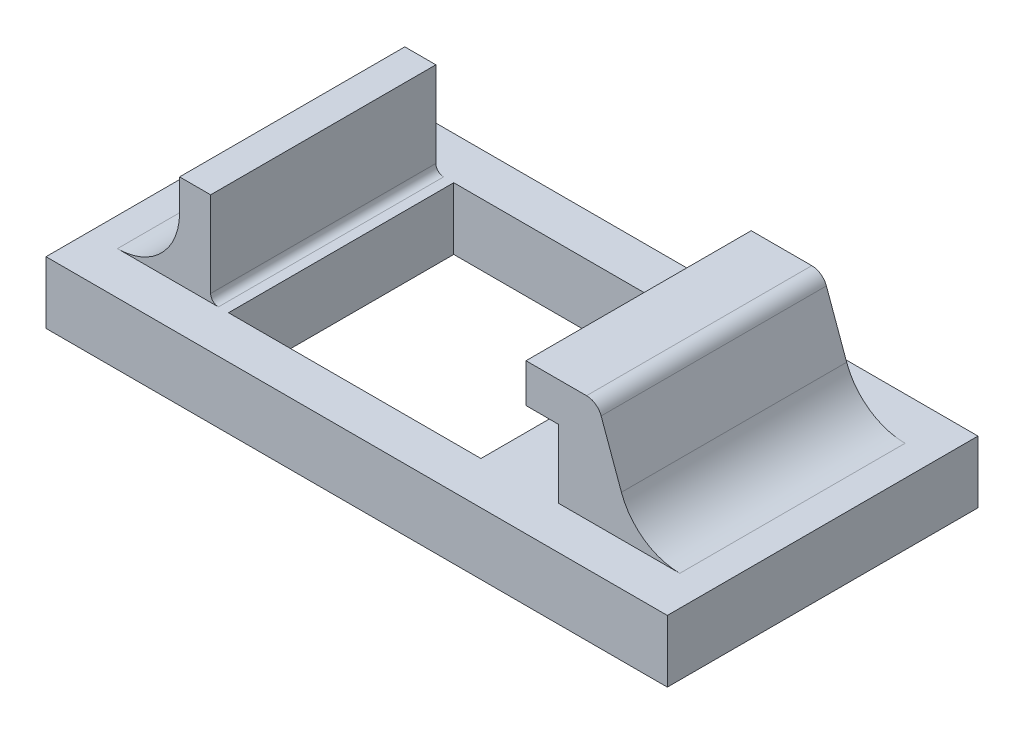
from build123d import *

# Parameters (mm, degrees)
SKETCH1_W           = 40
SKETCH1_H           = 20
BOSS_EXTRUDE1_DEPTH = 4
SKETCH2_W           = 16.25
SKETCH2_H           = 14.5
CUT_EXTRUDE2_DEPTH  = 3.5
SKETCH3_W           = 15.25
SKETCH3_H           = 14.5
CUT_EXTRUDE3_DEPTH  = 0.5
SKETCH4_W           = 2
SKETCH4_H           = 14.5
BOSS_EXTRUDE2_DEPTH = 6
FILLET1_R           = 4
FILLET2_R           = 0.5
SKETCH5_W           = 2.5
SKETCH5_H           = 14.5
BOSS_EXTRUDE3_DEPTH = 4.4
SKETCH6_W           = 4.6
SKETCH6_H           = 14.5
BOSS_EXTRUDE4_DEPTH = 2.5
BOSS_EXTRUDE5_DEPTH = 14.5
FILLET3_R           = 1
FILLET4_R           = 4


with BuildPart() as part:
    # Sketch1 → Boss-Extrude1 (new body)
    with BuildSketch(Plane(origin=(0, 0, 0), x_dir=(1, 0, 0), z_dir=(0, 1, 0))):
        Rectangle(SKETCH1_W, SKETCH1_H)
    extrude(amount=BOSS_EXTRUDE1_DEPTH)

    # Sketch2 → Cut-Extrude2 (cut)
    with BuildSketch(Plane(origin=(0, 4, 0), x_dir=(1, 0, 0), z_dir=(0, 1, 0))):
        with Locations((-2.875, 0)):
            Rectangle(SKETCH2_W, SKETCH2_H)
    extrude(amount=-CUT_EXTRUDE2_DEPTH, mode=Mode.SUBTRACT)

    # Sketch3 → Cut-Extrude3 (cut)
    with BuildSketch(Plane(origin=(0, 0.5, 0), x_dir=(1, 0, 0), z_dir=(0, 1, 0))):
        with Locations((-3.375, 0)):
            Rectangle(SKETCH3_W, SKETCH3_H)
    extrude(amount=-CUT_EXTRUDE3_DEPTH, mode=Mode.SUBTRACT)

    # Sketch4 → Boss-Extrude2 (add)
    with BuildSketch(Plane(origin=(0, 4, 0), x_dir=(1, 0, 0), z_dir=(0, 1, 0))):
        with Locations((-13.15, 0)):
            Rectangle(SKETCH4_W, SKETCH4_H)
    extrude(amount=BOSS_EXTRUDE2_DEPTH)

    # Fillet1
    fillet1_edges = [part.edges().sort_by_distance(p)[0] for p in [
        (-14.15, 4, 0),
    ]]
    fillet(fillet1_edges, radius=FILLET1_R)

    # Fillet2
    fillet2_edges = [part.edges().sort_by_distance(p)[0] for p in [
        (-12.15, 4, 0),
    ]]
    fillet(fillet2_edges, radius=FILLET2_R)

    # Sketch5 → Boss-Extrude3 (add)
    with BuildSketch(Plane(origin=(0, 4, 0), x_dir=(1, 0, 0), z_dir=(0, 1, 0))):
        with Locations((11.5, 0)):
            Rectangle(SKETCH5_W, SKETCH5_H)
    extrude(amount=BOSS_EXTRUDE3_DEPTH)

    # Sketch6 → Boss-Extrude4 (add)
    with BuildSketch(Plane(origin=(0, 8.4, 0), x_dir=(1, 0, 0), z_dir=(0, 1, 0))):
        with Locations((10.45, 0)):
            Rectangle(SKETCH6_W, SKETCH6_H)
    extrude(amount=BOSS_EXTRUDE4_DEPTH)

    # Sketch7 → Boss-Extrude5 (add)
    with BuildSketch(Plane.XY.offset(7.25)):
        Polygon((12.75, 4), (15.25, 4), (12.75, 10.9), align=None)
    extrude(amount=-BOSS_EXTRUDE5_DEPTH)

    # Fillet3
    fillet3_edges = [part.edges().sort_by_distance(p)[0] for p in [
        (12.75, 10.9, 0),
    ]]
    fillet(fillet3_edges, radius=FILLET3_R)

    # Fillet4
    fillet4_edges = [part.edges().sort_by_distance(p)[0] for p in [
        (15.25, 4, 0),
    ]]
    fillet(fillet4_edges, radius=FILLET4_R)


solid = part.part
